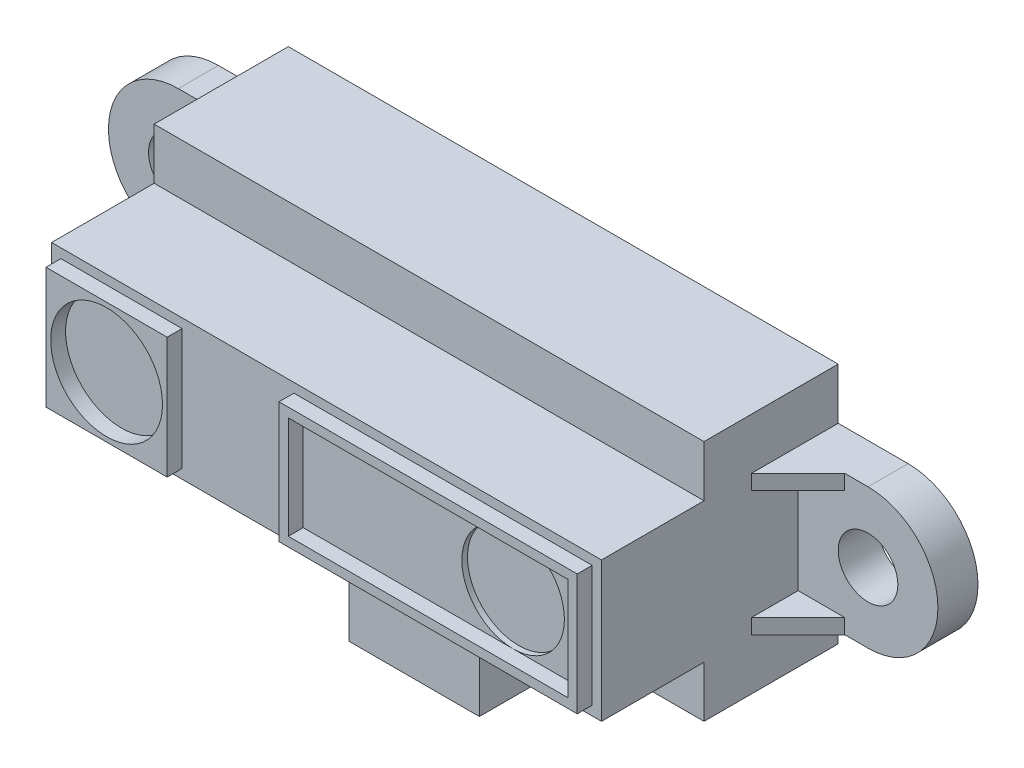
from build123d import *

# Parameters (mm, degrees)
SKETCH_1_W          = 29.5
SKETCH_1_H          = 7.5
EXTRUDE_1_DEPTH     = 13.5
SKETCH_1_4_R        = 1.6
EXTRUDE_2_DEPTH     = 2.15
EXTRUDE_3_DEPTH     = 0.8
EXTRUDE_4_DEPTH     = 0.8
SKETCH_4_W          = 29.5
SKETCH_4_H          = 7.5
SKETCH_4_W_2        = 6.5
SKETCH_4_H_2        = 6.5
SKETCH_4_W_3        = 16
SKETCH_4_W_4        = 15
SKETCH_4_H_3        = 5.5
SKETCH_4_R          = 3
CUT_EXTRUDE_1_DEPTH = 0.8
SKETCH_7_W          = 29.5
SKETCH_7_H          = 13
EXTRUDE_5_DEPTH     = 7.2
SKETCH_10_W         = 10.1
SKETCH_10_H         = 1.2
SKETCH_10_W_2       = 7
SKETCH_10_H_2       = 2.7
SKETCH_10_H_3       = 0.8
EXTRUDE_7_DEPTH     = 7.75
SKETCH_11_W         = 5.595198372
SKETCH_11_H         = 2.7
SKETCH_11_W_2       = 0.4
CUT_EXTRUDE_2_DEPTH = 7.75
SKETCH_12_R         = 2.75
CUT_EXTRUDE_3_DEPTH = 0.3


with BuildPart() as part:
    # 草图1 → 凸台-拉伸1 (new body)
    with BuildSketch(Plane.XY):
        Rectangle(SKETCH_1_W, SKETCH_1_H)
    extrude(amount=EXTRUDE_1_DEPTH)

    # 草图1<4> → 凸台-拉伸2 (add)
    with BuildSketch(Plane.XY):
        with BuildLine():
            Line((-18.5, -3.75), (-14.75, -3.75))
            Line((-14.75, -3.75), (-14.75, 3.75))
            Line((-14.75, 3.75), (-18.5, 3.75))
            ThreePointArc((-18.5, 3.75), (-22.25, 0), (-18.5, -3.75))
        make_face()
        with Locations((-18.5, 0)):
            Circle(SKETCH_1_4_R, mode=Mode.SUBTRACT)
        with BuildLine():
            Line((14.75, -3.75), (18.5, -3.75))
            ThreePointArc((18.5, -3.75), (22.25, 0), (18.5, 3.75))
            Line((18.5, 3.75), (14.75, 3.75))
            Line((14.75, 3.75), (14.75, -3.75))
        make_face()
        with Locations((18.5, 0)):
            Circle(SKETCH_1_4_R, mode=Mode.SUBTRACT)
    extrude(amount=EXTRUDE_2_DEPTH)

    # 草图2 → 凸台-拉伸3 (add)
    with BuildSketch(Plane.XZ.offset(3.75)):
        Polygon((-14.75, 4.65), (-17.25, 2.15), (-14.75, 2.15), align=None)
        Polygon((14.75, 4.65), (17.25, 2.15), (14.75, 2.15), align=None)
    extrude(amount=-EXTRUDE_3_DEPTH)

    # 草图3 → 凸台-拉伸4 (add)
    with BuildSketch(Plane(origin=(0, 3.75, 0), x_dir=(1, 0, 0), z_dir=(0, 1, 0))):
        Polygon((17.25, -2.15), (14.75, -2.15), (14.75, -4.65), align=None)
        Polygon((-14.75, -4.65), (-14.75, -2.15), (-17.25, -2.15), align=None)
    extrude(amount=-EXTRUDE_4_DEPTH)

    # 草图4 → 切除-拉伸1 (cut)
    with BuildSketch(Plane.XY.offset(13.5)):
        Rectangle(SKETCH_4_W, SKETCH_4_H)
        with Locations((-11, 0)):
            Rectangle(SKETCH_4_W_2, SKETCH_4_H_2, mode=Mode.SUBTRACT)
        with Locations((6.25, 0)):
            Rectangle(SKETCH_4_W_3, SKETCH_4_H_2, mode=Mode.SUBTRACT)
        with Locations((6.25, 0)):
            Rectangle(SKETCH_4_W_4, SKETCH_4_H_3)
        with Locations((-11, 0)):
            Circle(SKETCH_4_R)
    extrude(amount=-CUT_EXTRUDE_1_DEPTH, mode=Mode.SUBTRACT)

    # 草图7 → 凸台-拉伸5 (add)
    with BuildSketch(Plane.XY):
        Rectangle(SKETCH_7_W, SKETCH_7_H)
    extrude(amount=EXTRUDE_5_DEPTH)

    # 草图10 → 凸台-拉伸7 (add)
    with BuildSketch(Plane.XZ.offset(3.75)):
        with Locations((0, 3.9)):
            Rectangle(SKETCH_10_W, SKETCH_10_H)
        with Locations((0, 5.85)):
            Rectangle(SKETCH_10_W_2, SKETCH_10_H_2)
        with Locations((0, 7.6)):
            Rectangle(SKETCH_10_W_2, SKETCH_10_H_3)
    extrude(amount=EXTRUDE_7_DEPTH)

    # 草图11 → 切除-拉伸2 (cut)
    with BuildSketch(Plane.XZ.offset(11.5)):
        with Locations((0, 5.85)):
            Rectangle(SKETCH_11_W, SKETCH_11_H)
        with Locations((3.7, 5.85)):
            Rectangle(SKETCH_11_W_2, SKETCH_11_H)
        with Locations((-3.707390598, 5.85)):
            Rectangle(SKETCH_11_W_2, SKETCH_11_H)
    extrude(amount=-CUT_EXTRUDE_2_DEPTH, mode=Mode.SUBTRACT)

    # 草图12 → 切除-拉伸3 (cut)
    with BuildSketch(Plane.XY.offset(12.7)):
        with Locations((10.011243367, 0)):
            Circle(SKETCH_12_R)
    extrude(amount=-CUT_EXTRUDE_3_DEPTH, mode=Mode.SUBTRACT)


solid = part.part
